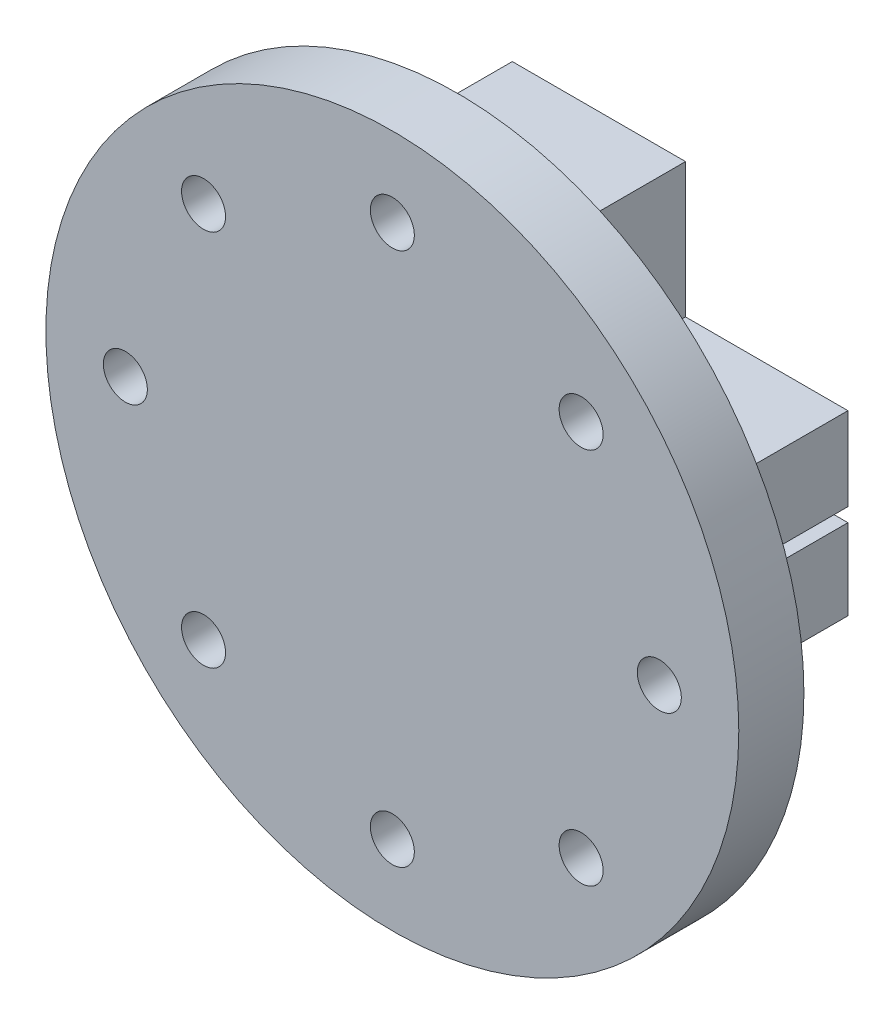
from build123d import *

# Parameters (mm, degrees)
SKETCH_1_W           = 30
SKETCH_1_H           = 14.828427124
EXTRUDE_2_DEPTH      = 25.5
CUT_EXTRUDE_9_DEPTH  = 46
CUT_EXTRUDE_10_DEPTH = 30
CUT_EXTRUDE_11_DEPTH = 31
CUT_EXTRUDE_12_DEPTH = 40
CUT_EXTRUDE_13_DEPTH = 46
CUT_EXTRUDE_17_DEPTH = 97
CUT_EXTRUDE_18_DEPTH = 285
SKETCH_12_R          = 50
EXTRUDE_7_DEPTH      = 9.398
SKETCH_16_W          = 11
SKETCH_16_H          = 2
CUT_EXTRUDE_25_DEPTH = 25.5
SKETCH_12_5_R        = 3.175
CUT_EXTRUDE_27_DEPTH = 63
EXTRUDE_9_DEPTH      = 26
SKETCH_20_8_W        = 10
SKETCH_20_8_H        = 2
EXTRUDE_10_DEPTH     = 26
SKETCH_21_R          = 3.175
CUT_EXTRUDE_28_DEPTH = 54
SKETCH_22_W          = 23.435889716
SKETCH_22_H          = 10
CUT_EXTRUDE_31_DEPTH = 25.5
SKETCH_1_26_W        = 0.7
SKETCH_1_26_H        = 1
CUT_EXTRUDE_32_DEPTH = 25.5


with BuildPart() as part:
    # 草图1 → 凸台-拉伸2 (new body)
    with BuildSketch(Plane.XY):
        with Locations((7.585786438, 0)):
            Rectangle(SKETCH_1_W, SKETCH_1_H)
    extrude(amount=EXTRUDE_2_DEPTH)

    # 草图1<11> → 切除-拉伸9 (cut)
    with BuildSketch(Plane.XY):
        with BuildLine():
            Line((0, -2), (0, 0))
            Line((0, 0), (-6, 0))
            ThreePointArc((-6, 0), (-4.242640687, -4.242640687), (0, -6))
            ThreePointArc((0, -6), (3.464101615, -4.898979486), (5.656854249, -2))
            Line((5.656854249, -2), (0, -2))
        make_face()
    extrude(amount=CUT_EXTRUDE_9_DEPTH, mode=Mode.SUBTRACT)

    # 草图1<12> → 切除-拉伸10 (cut)
    with BuildSketch(Plane.XY):
        with BuildLine():
            Line((-6, 0), (0, 0))
            Line((0, 0), (0, 2))
            Line((0, 2), (0, 6))
            ThreePointArc((0, 6), (-4.242640687, 4.242640687), (-6, 0))
        make_face()
    extrude(amount=CUT_EXTRUDE_10_DEPTH, mode=Mode.SUBTRACT)

    # 草图1<13> → 切除-拉伸11 (cut)
    with BuildSketch(Plane.XY):
        with BuildLine():
            Line((0, 2), (0, 0))
            Line((0, 0), (6, 0))
            ThreePointArc((6, 0), (5.913591358, 1.014611872), (5.656854249, 2))
            Line((5.656854249, 2), (0, 2))
        make_face()
    extrude(amount=CUT_EXTRUDE_11_DEPTH, mode=Mode.SUBTRACT)

    # 草图1<14> → 切除-拉伸12 (cut)
    with BuildSketch(Plane.XY):
        with BuildLine():
            Line((6, 0), (0, 0))
            Line((0, 0), (0, -2))
            Line((0, -2), (5.656854249, -2))
            ThreePointArc((5.656854249, -2), (5.913591358, -1.014611872), (6, 0))
        make_face()
    extrude(amount=CUT_EXTRUDE_12_DEPTH, mode=Mode.SUBTRACT)

    # 草图1<15> → 切除-拉伸13 (cut)
    with BuildSketch(Plane.XY):
        with BuildLine():
            Line((0, 6), (0, 2))
            Line((0, 2), (5.656854249, 2))
            ThreePointArc((5.656854249, 2), (3.464101615, 4.898979486), (0, 6))
        make_face()
    extrude(amount=CUT_EXTRUDE_13_DEPTH, mode=Mode.SUBTRACT)

    # 草图1<19> → 切除-拉伸17 (cut)
    with BuildSketch(Plane.XY):
        with BuildLine():
            Line((7, 2), (5.656854249, 2))
            ThreePointArc((5.656854249, 2), (6, 0), (5.656854249, -2))
            Line((5.656854249, -2), (7, -2))
            Line((7, -2), (7, 2))
        make_face()
    extrude(amount=CUT_EXTRUDE_17_DEPTH, mode=Mode.SUBTRACT)

    # 草图1<20> → 切除-拉伸18 (cut)
    with BuildSketch(Plane.XY):
        with BuildLine():
            ThreePointArc((7.414213562, 7.414213562), (9.005239827, 5.370919954), (10.046946078, 3))
            Line((10.046946078, 3), (18, 3))
            Line((18, 3), (20.850103278, 3))
            Line((20.850103278, 3), (20.850103278, 1))
            Line((20.850103278, 1), (18, 1))
            Line((18, 1), (18, -1))
            Line((18, -1), (20.850103278, -1))
            Line((20.850103278, -1), (20.850103278, -3))
            Line((20.850103278, -3), (18, -3))
            Line((18, -3), (10.046946078, -3))
            ThreePointArc((10.046946078, -3), (9.005239827, -5.370919954), (7.414213562, -7.414213562))
            Line((7.414213562, -7.414213562), (22.585786438, -7.414213562))
            Line((22.585786438, -7.414213562), (22.585786438, 7.414213562))
            Line((22.585786438, 7.414213562), (7.414213562, 7.414213562))
        make_face()
    extrude(amount=CUT_EXTRUDE_18_DEPTH, mode=Mode.SUBTRACT)

    # 草图12 → 凸台-拉伸7 (add)
    with BuildSketch(Plane.XY.offset(25.5)):
        Circle(SKETCH_12_R)
    extrude(amount=EXTRUDE_7_DEPTH)

    # 草图16 → 切除-拉伸25 (cut)
    with BuildSketch(Plane(origin=(0, 0, 0), x_dir=(-1, 0, 0), z_dir=(0, 0, -1))):
        with Locations((-12.5, 0)):
            Rectangle(SKETCH_16_W, SKETCH_16_H)
    extrude(amount=-CUT_EXTRUDE_25_DEPTH, mode=Mode.SUBTRACT)

    # 草图12<5> → 切除-拉伸27 (cut)
    with BuildSketch(Plane.XY.offset(25.5)):
        with Locations((0, 38.530339059)):
            Circle(SKETCH_12_5_R)
        with Locations((-27.24506403, 27.24506403)):
            Circle(SKETCH_12_5_R)
        with Locations((27.24506403, -27.24506403)):
            Circle(SKETCH_12_5_R)
        with Locations((-38.530339059, 0)):
            Circle(SKETCH_12_5_R)
        with Locations((38.530339059, 0)):
            Circle(SKETCH_12_5_R)
        with Locations((0, -38.530339059)):
            Circle(SKETCH_12_5_R)
        with Locations((-27.24506403, -27.24506403)):
            Circle(SKETCH_12_5_R)
        with Locations((27.24506403, 27.24506403)):
            Circle(SKETCH_12_5_R)
    extrude(amount=CUT_EXTRUDE_27_DEPTH, mode=Mode.SUBTRACT)

    # 草图20 → 凸台-拉伸9 (add)
    with BuildSketch(Plane(origin=(0, 0, 0), x_dir=(-1, 0, 0), z_dir=(0, 0, -1))):
        Polygon((-7.414213562, 32.414213562), (-7.414213562, 23), (-30.850103278, 23), (-30.850103278, 3), (-7.414213562, 3), (-7.414213562, 7.414213562), (7.414213562, 7.414213562), (7.414213562, -7.414213562), (-7.414213562, -7.414213562), (-7.414213562, -3), (-30.850103278, -3), (-30.850103278, -22.641492006), (-7.414213562, -22.641492006), (-7.414213562, -32.414213562), (17.585786438, -32.414213562), (17.585786438, 32.414213562), align=None)
    extrude(amount=-EXTRUDE_9_DEPTH)

    # 草图20<8> → 凸台-拉伸10 (add)
    with BuildSketch(Plane(origin=(0, 0, 0), x_dir=(-1, 0, 0), z_dir=(0, 0, -1))):
        with Locations((-25.850103278, 2)):
            Rectangle(SKETCH_20_8_W, SKETCH_20_8_H)
        with Locations((-25.850103278, -2)):
            Rectangle(SKETCH_20_8_W, SKETCH_20_8_H)
    extrude(amount=-EXTRUDE_10_DEPTH)

    # 草图21 → 切除-拉伸28 (cut)
    with BuildSketch(Plane.XZ.offset(22.641492006)):
        with Locations((19.13215842, 12.75)):
            Circle(SKETCH_21_R)
    extrude(amount=-CUT_EXTRUDE_28_DEPTH, mode=Mode.SUBTRACT)

    # 草图22 → 切除-拉伸31 (cut)
    with BuildSketch(Plane(origin=(0, 0, 0), x_dir=(-1, 0, 0), z_dir=(0, 0, -1))):
        with Locations((-19.13215842, -17.641492006)):
            Rectangle(SKETCH_22_W, SKETCH_22_H)
        with Locations((-19.13215842, 18)):
            Rectangle(SKETCH_22_W, SKETCH_22_H)
    extrude(amount=-CUT_EXTRUDE_31_DEPTH, mode=Mode.SUBTRACT)

    # 草图1<26> → 切除-拉伸32 (cut)
    with BuildSketch(Plane.XY):
        with Locations((7.35, -1.5)):
            Rectangle(SKETCH_1_26_W, SKETCH_1_26_H)
        with Locations((7.35, 1.5)):
            Rectangle(SKETCH_1_26_W, SKETCH_1_26_H)
    extrude(amount=CUT_EXTRUDE_32_DEPTH, mode=Mode.SUBTRACT)


solid = part.part
